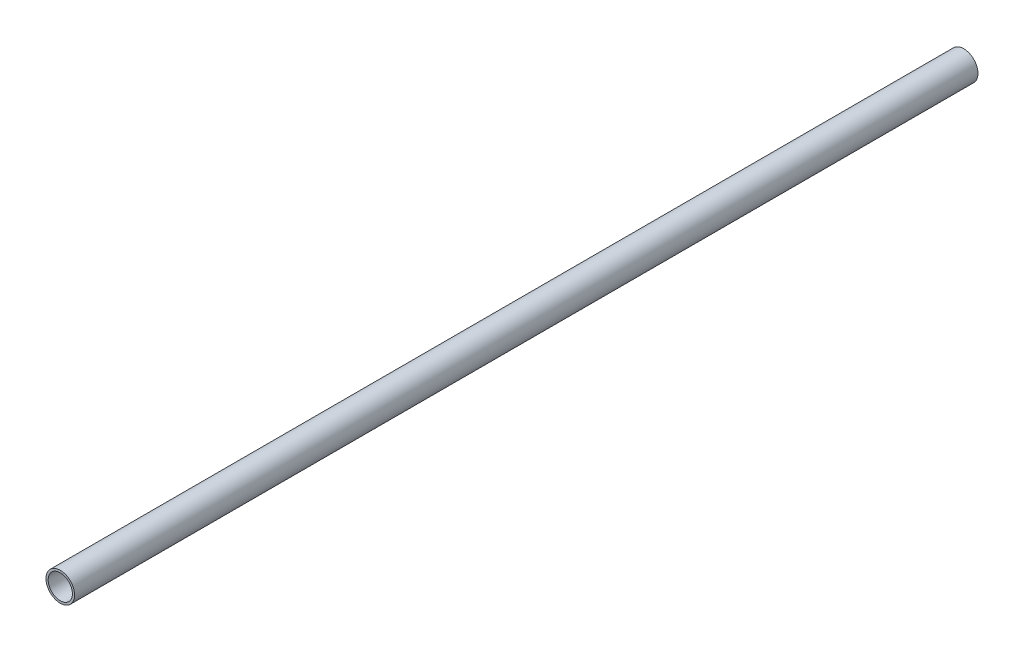
from build123d import *

# Parameters (mm, degrees)
SKETCH1_R           = 24.13
SKETCH1_R_2         = 20.447
EXTRUDE_THIN1_DEPTH = 762


with BuildPart() as part:
    # Sketch1 → Extrude-Thin1 (new body, symmetric)
    with BuildSketch(Plane.XY):
        Circle(SKETCH1_R)
        Circle(SKETCH1_R_2, mode=Mode.SUBTRACT)
    extrude(amount=EXTRUDE_THIN1_DEPTH, both=True)


solid = part.part
